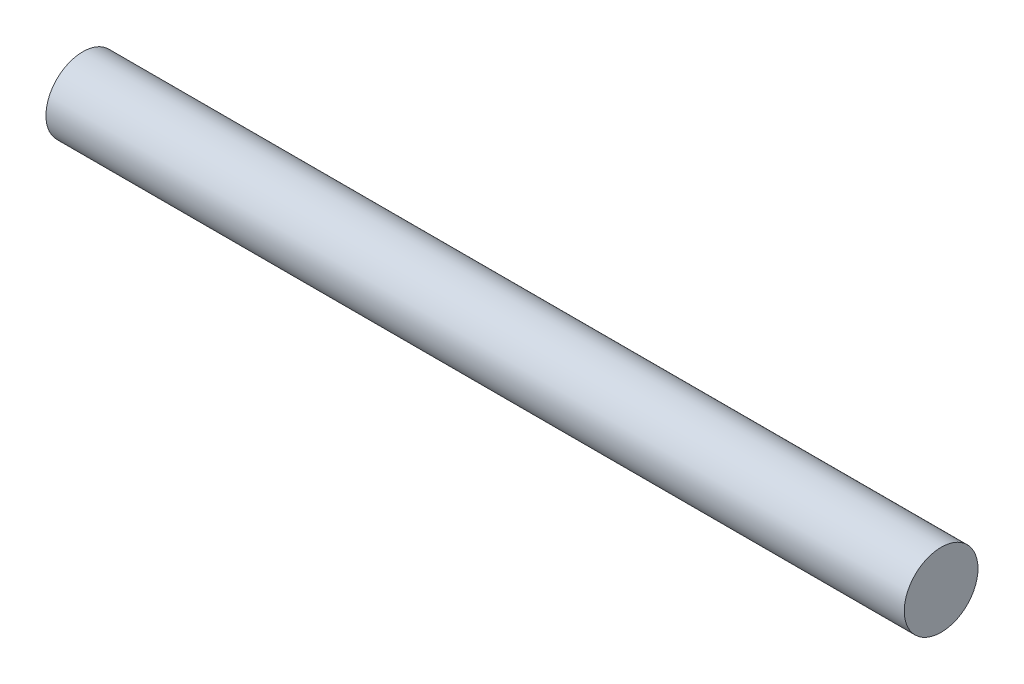
from build123d import *

# Parameters (mm, degrees)
SKETCH1_R           = 2.75
BOSS_EXTRUDE1_DEPTH = 32


with BuildPart() as part:
    # Sketch1 → Boss-Extrude1 (new body, symmetric)
    with BuildSketch(Plane(origin=(0, 0, 0), x_dir=(0, 0, -1), z_dir=(1, 0, 0))):
        Circle(SKETCH1_R)
    extrude(amount=BOSS_EXTRUDE1_DEPTH, both=True)


solid = part.part
